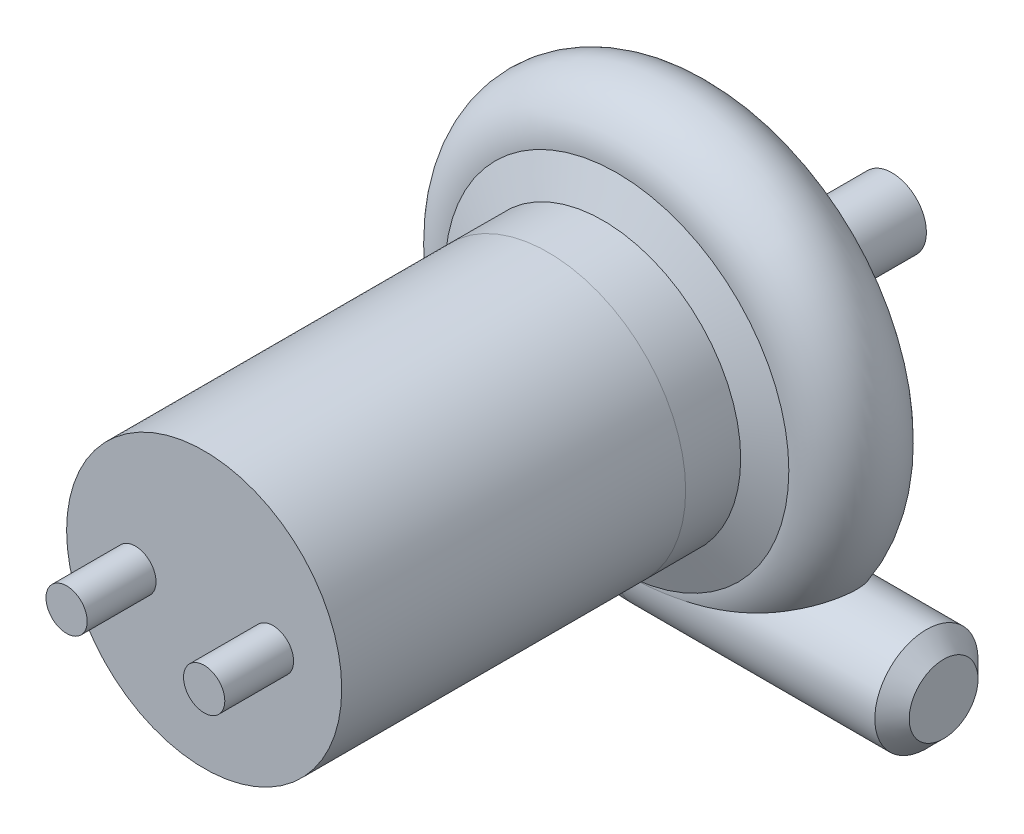
from build123d import *

# Parameters (mm, degrees)
SKETCH1_R           = 20
BOSS_EXTRUDE1_DEPTH = 50
SKETCH4_R           = 7.5
BOSS_EXTRUDE2_DEPTH = 40
CHAMFER1_SIZE       = 2.5
SKETCH6_R           = 3
BOSS_EXTRUDE4_DEPTH = 10


with BuildPart() as part:
    # Sketch1 → Boss-Extrude1 (new body)
    with BuildSketch(Plane.XY):
        Circle(SKETCH1_R)
    extrude(amount=BOSS_EXTRUDE1_DEPTH)

    # Sketch6 → Boss-Extrude4 (add)
    with BuildSketch(Plane.XY.offset(50)):
        with Locations((10, 0)):
            Circle(SKETCH6_R)
        with Locations((-10, 0)):
            Circle(SKETCH6_R)
    extrude(amount=BOSS_EXTRUDE4_DEPTH)


with BuildPart() as body_2:
    # Sketch3 → Revolve1 (revolve)
    with BuildSketch(Plane(origin=(0, 0, 0), x_dir=(0, 0, -1), z_dir=(1, 0, 0)), mode=Mode.PRIVATE) as revolve1_sk:
        with BuildLine():
            Line((0, 0), (0, 20))
            Line((0, 20), (8, 20))
            Line((8, 20), (10, 25))
            ThreePointArc((10, 25), (17.5, 32.5), (25, 25))
            Line((25, 25), (25, 15))
            Line((25, 15), (35, 10))
            Line((35, 10), (35, 5))
            Line((35, 5), (50, 5))
            Line((50, 5), (50, 0))
            Line((50, 0), (0, 0))
        make_face()
    revolve(revolve1_sk.sketch.rotate(Axis((0, 0, 0), (0, 0, -1)), 90), axis=Axis((0, 0, 0), (0, 0, -1)))

    # Sketch4 → Boss-Extrude2 (add)
    with BuildSketch(Plane(origin=(0, 0, 0), x_dir=(0, 0, -1), z_dir=(1, 0, 0))):
        with Locations((17.5, -25)):
            Circle(SKETCH4_R)
    extrude(amount=BOSS_EXTRUDE2_DEPTH)

    # Chamfer1
    chamfer1_edges = [body_2.edges().sort_by_distance(p)[0] for p in [
        (40, -25, -10),
    ]]
    chamfer(chamfer1_edges, length=CHAMFER1_SIZE)


solid = Compound([part.part, body_2.part])
